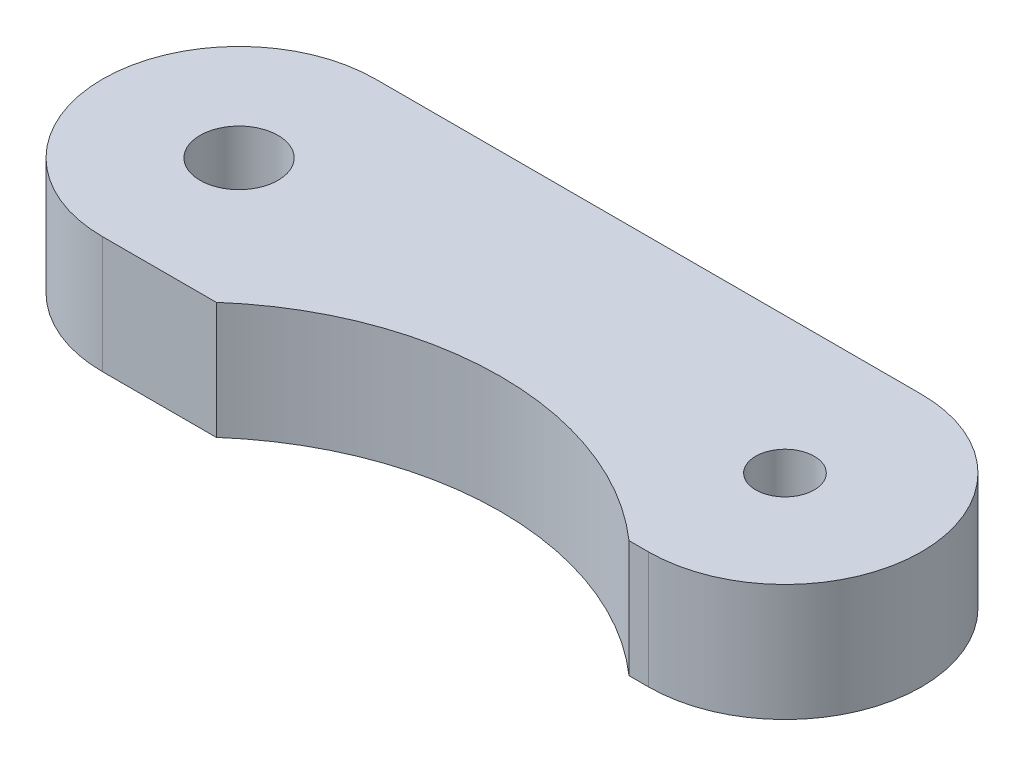
from build123d import *

# Parameters (mm, degrees)
SKETCH1_R           = 0.75
SKETCH1_R_2         = 1
BOSS_EXTRUDE1_DEPTH = 3
CUT_EXTRUDE1_DEPTH  = 10


with BuildPart() as part:
    # Sketch1 → Boss-Extrude1 (new body)
    with BuildSketch(Plane(origin=(0, 0, 0), x_dir=(1, 0, 0), z_dir=(0, 1, 0))):
        with BuildLine():
            Line((0, 3.5), (14, 3.5))
            ThreePointArc((14, 3.5), (17.5, 0), (14, -3.5))
            Line((14, -3.5), (0, -3.5))
            ThreePointArc((0, -3.5), (-3.5, 0), (0, 3.5))
        make_face()
        with Locations((14, 0)):
            Circle(SKETCH1_R, mode=Mode.SUBTRACT)
        Circle(SKETCH1_R_2, mode=Mode.SUBTRACT)
    extrude(amount=BOSS_EXTRUDE1_DEPTH)

    # Sketch2 → Cut-Extrude1 (cut)
    with BuildSketch(Plane(origin=(0, 3, 0), x_dir=(1, 0, 0), z_dir=(0, 1, 0))):
        with BuildLine():
            Line((2.916994756, -3.5), (13.5, -3.5))
            ThreePointArc((13.5, -3.5), (8.208497378, -1.5), (2.916994756, -3.5))
        make_face()
    extrude(amount=-CUT_EXTRUDE1_DEPTH, mode=Mode.SUBTRACT)


solid = part.part
